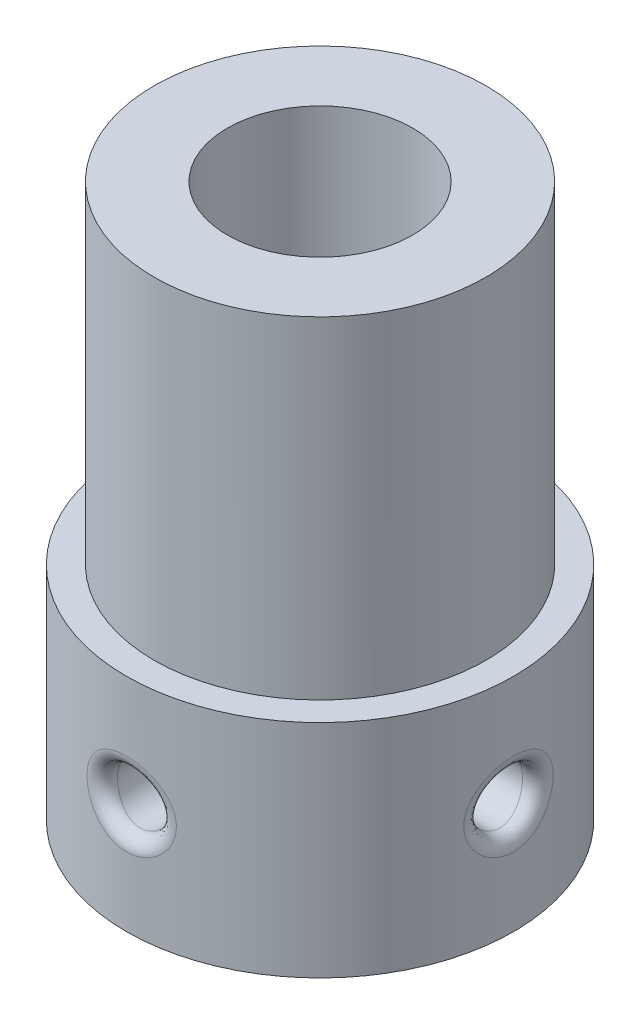
from build123d import *

# Parameters (mm, degrees)
SKETCH1_R               = 7
BOSS_EXTRUDE1_DEPTH     = 8
SKETCH2_R               = 6
BOSS_EXTRUDE2_DEPTH     = 14
SKETCH6_R               = 3
CUT_EXTRUDE2_DEPTH      = 20
CUT_EXTRUDE3_REACH      = 29
CUT_EXTRUDE3_END_RADIUS = 3
SKETCH8_R               = 1
CIRPATTERN1_COUNT       = 2
CIRPATTERN1_ANGLE       = 90
FILLET1_R               = 0.5
SKETCH3_R               = 7
CUT_EXTRUDE_2_DEPTH     = 2
SCALE_1_SCALE           = 0.894736842
SKETCH_1_R              = 3
CUT_EXTRUDE_3_DEPTH     = 20.969059417


with BuildPart() as part:
    # Sketch1 → Boss-Extrude1 (new body)
    with BuildSketch(Plane(origin=(0, 0, 0), x_dir=(1, 0, 0), z_dir=(0, 1, 0))):
        with Locations(Location((0, 0, 0), (0, 0, 270))):
            Circle(SKETCH1_R)
    extrude(amount=BOSS_EXTRUDE1_DEPTH)

    # Sketch2 → Boss-Extrude2 (add)
    with BuildSketch(Plane(origin=(0, 8, 0), x_dir=(1, 0, 0), z_dir=(0, 1, 0))):
        with Locations(Location((0, 0, 0), (0, 0, 270))):
            Circle(SKETCH2_R)
    extrude(amount=BOSS_EXTRUDE2_DEPTH)

    # Sketch6 → Cut-Extrude2 (cut)
    with BuildSketch(Plane.XZ):
        with Locations(Location((0, 0, 0), (0, 0, 270))):
            Circle(SKETCH6_R)
    extrude(amount=-CUT_EXTRUDE2_DEPTH, mode=Mode.SUBTRACT)

    # Cut-Extrude3: up to this cylinder (the profile starts outside it)
    cut_extrude3_end = Plane(origin=(0, 4, 0), z_dir=(0, -1, 0)) * Cylinder(CUT_EXTRUDE3_END_RADIUS, 65, mode=Mode.PRIVATE)
    # Sketch8 → Cut-Extrude3 (cut, up to the surface)
    with BuildSketch(Plane.XY.offset(7), mode=Mode.PRIVATE) as cut_extrude3_sk1:
        with Locations((0, 4)):
            Circle(SKETCH8_R)
    cut_extrude3_tool1 = extrude(cut_extrude3_sk1.sketch, amount=-CUT_EXTRUDE3_REACH, mode=Mode.PRIVATE) - cut_extrude3_end
    cut_extrude3 = cut_extrude3_tool1.solids().sort_by_distance((0, 4, 7))[0]
    add(cut_extrude3, mode=Mode.SUBTRACT)

    # CirPattern1: Cut-Extrude3 ×2 about axis
    cirpattern1_axis = Axis((0, 0, 0), (0, 1, 0))
    for i in range(1, CIRPATTERN1_COUNT):
        add(cut_extrude3.rotate(cirpattern1_axis, i * CIRPATTERN1_ANGLE / (CIRPATTERN1_COUNT - 1)), mode=Mode.SUBTRACT)

    # Fillet1
    fillet1_edges = [part.edges().sort_by_distance(p)[0] for p in [
        (-1, 4, 6.92820323),
        (6.92820323, 4, 1),
    ]]
    fillet(fillet1_edges, radius=FILLET1_R)

    # Sketch3 → ｶｯﾄ - 押し出し2 (cut)
    with BuildSketch(Plane(origin=(0, 22, 0), x_dir=(1, 0, 0), z_dir=(0, 1, 0))):
        with Locations(Location((0, 0, 0), (0, 0, 270))):
            Circle(SKETCH3_R)
    extrude(amount=-CUT_EXTRUDE_2_DEPTH, mode=Mode.SUBTRACT)


with BuildPart() as part_1:
    # ｽｹｰﾙ1: scaled about (-0.033116377, 9.097196925, -0.033121406)
    add(part.part.scale(SCALE_1_SCALE).moved(Location((-0.003485934, 0.957599676, -0.003486464))))

    # ｽｹｯﾁ1 → ｶｯﾄ - 押し出し3 (cut, through all)
    with BuildSketch(Plane.XZ.offset(-0.957597864)):
        with Locations(Location((0, 0, 0), (0, 0, 270))):
            Circle(SKETCH_1_R)
    extrude(amount=-CUT_EXTRUDE_3_DEPTH, mode=Mode.SUBTRACT)


solid = part_1.part
